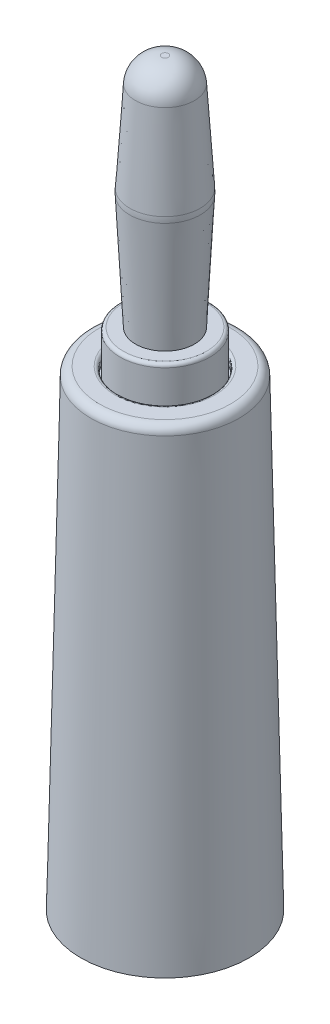
from build123d import *

# Parameters (mm, degrees)
SKETCH2_R          = 2.55
CUT_EXTRUDE1_DEPTH = 11
SHELL7_T           = -0.1
SKETCH4_R          = 1.2
CUT_EXTRUDE2_DEPTH = 33.369816286
SKETCH5_R          = 1.2
CUT_EXTRUDE3_DEPTH = 33.369816307
FILLET1_R          = 0.2
FILLET2_R          = 0.2
FILLET3_R          = 0.5


with BuildPart() as part:
    # Sketch1 → Revolve1 (revolve)
    with BuildSketch(Plane.XY, mode=Mode.PRIVATE) as revolve1_sk:
        Polygon((0, 0), (0, 18), (2.68, 18), (2.68, 13.77), (3.45, 13), (3.45, 0), align=None)
    revolve(revolve1_sk.sketch.rotate(Axis((0, 0, 0), (0, 1, 0)), 90), axis=Axis((0, 0, 0), (0, 1, 0)))

    # Sketch2 → Cut-Extrude1 (cut)
    with BuildSketch(Plane.XZ):
        with Locations(Location((0, 0, 0), (0, 0, 270))):
            Circle(SKETCH2_R)
    extrude(amount=-CUT_EXTRUDE1_DEPTH, mode=Mode.SUBTRACT)

    # Sketch4 → Cut-Extrude2 (cut, through all)
    with BuildSketch(Plane.XY):
        with Locations(Location((0, 3, 0), (0, 0, 180))):
            Circle(SKETCH4_R)
    extrude(amount=CUT_EXTRUDE2_DEPTH, mode=Mode.SUBTRACT)

    # Sketch5 → Cut-Extrude3 (cut, through all)
    with BuildSketch(Plane.XY):
        with Locations(Location((0, 8, 0), (0, 0, 90))):
            Circle(SKETCH5_R)
    extrude(amount=-CUT_EXTRUDE3_DEPTH, mode=Mode.SUBTRACT)

    # Fillet1
    fillet1_edges = [part.edges().sort_by_distance(p)[0] for p in [
        (0, 18, 2.68),
        (0, 13.77, 2.68),
        (0, 13, 3.45),
    ]]
    fillet(fillet1_edges, radius=FILLET1_R)


with BuildPart() as body_2:
    # Sketch3 → Revolve2 (revolve)
    with BuildSketch(Plane.XY, mode=Mode.PRIVATE) as revolve2_sk:
        with BuildLine():
            Line((0, 18), (0, 32))
            Line((0, 32), (0.2, 32))
            ThreePointArc((0.2, 32), (1.262608009, 31.579615074), (1.75, 30.546025061))
            Line((1.75, 30.546025061), (2.09394114, 25.171725799))
            ThreePointArc((2.09394114, 25.171725799), (2.1, 25), (2.096216922, 24.828208998))
            Line((2.096216922, 24.828208998), (1.75, 18))
            Line((1.75, 18), (0, 18))
        make_face()
    revolve(revolve2_sk.sketch.rotate(Axis((0, 18, 0), (0, 1, 0)), 90), axis=Axis((0, 18, 0), (0, 1, 0)))

    # Shell7
    shell7_openings = [body_2.faces().sort_by_distance(p)[0] for p in [
        (0, 18, 0),
    ]]
    offset(amount=SHELL7_T, openings=shell7_openings, kind=Kind.INTERSECTION)


with BuildPart() as body_3:
    # Sketch6 → Revolve3 (revolve)
    with BuildSketch(Plane.XY, mode=Mode.PRIVATE) as revolve3_sk:
        Polygon((4, -12), (5, -12), (4.4, 16), (2.78, 16), (2.78, 15.5), (2.68, 15.5), (2.68, 14), (3.68, 13), align=None)
    revolve(revolve3_sk.sketch.rotate(Axis((0, 15.5, 0), (0, -1, 0)), 180), axis=Axis((0, 15.5, 0), (0, -1, 0)))

    # Fillet2
    fillet2_edges = [body_3.edges().sort_by_distance(p)[0] for p in [
        (2.78, 16, 0),
    ]]
    fillet(fillet2_edges, radius=FILLET2_R)

    # Fillet3
    fillet3_edges = [body_3.edges().sort_by_distance(p)[0] for p in [
        (4.4, 16, 0),
    ]]
    fillet(fillet3_edges, radius=FILLET3_R)


solid = Compound([part.part, body_2.part, body_3.part])
